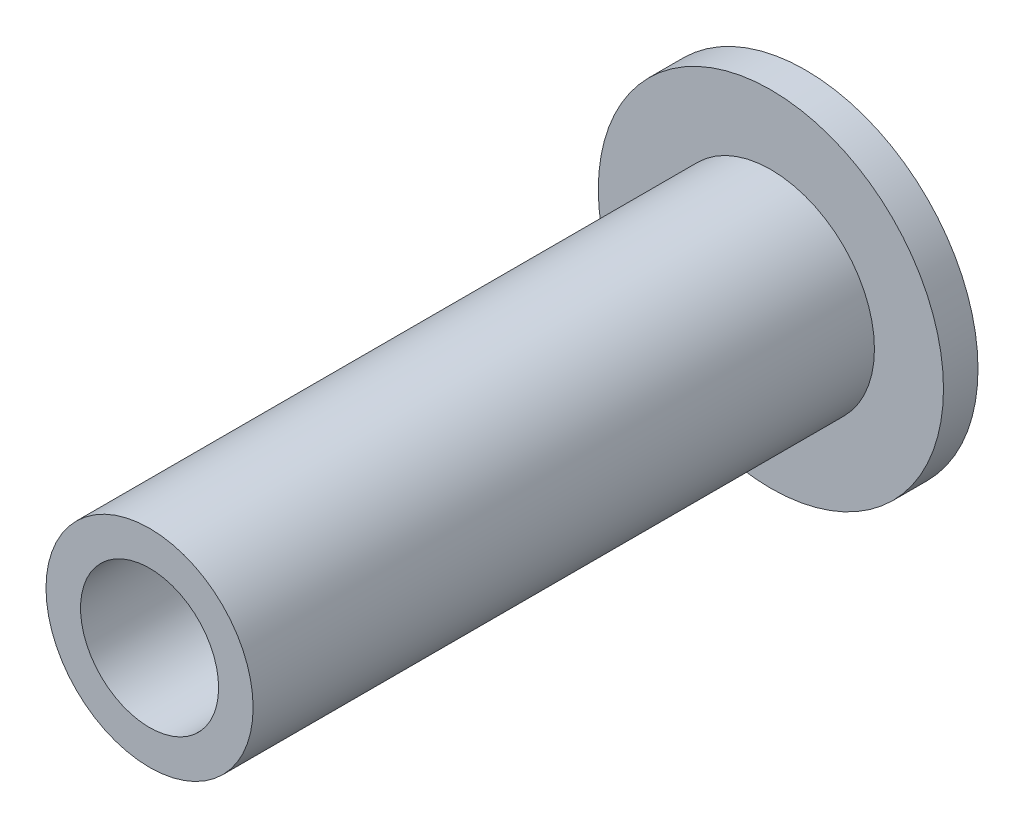
from build123d import *


with BuildPart() as part:
    # Esquisse1 → Révolution1 (revolve)
    with BuildSketch(Plane(origin=(0, 0, 0), x_dir=(0, 0, -1), z_dir=(1, 0, 0))):
        with BuildLine():
            Line((-18, 3), (0, 3))
            Line((0, 3), (0, 5))
            Line((0, 5), (1, 5))
            ThreePointArc((1, 5), (1.357034349, 2.511322427), (1.47640459, 0))
            Line((1.47640459, 0), (0, 0))
            Line((0, 0), (-1.154700538, 2))
            Line((-1.154700538, 2), (-18, 2))
            Line((-18, 2), (-18, 3))
        make_face()
    revolve(axis=Axis((0, 0, 27.655172414), (0, 0, -1)))


solid = part.part
